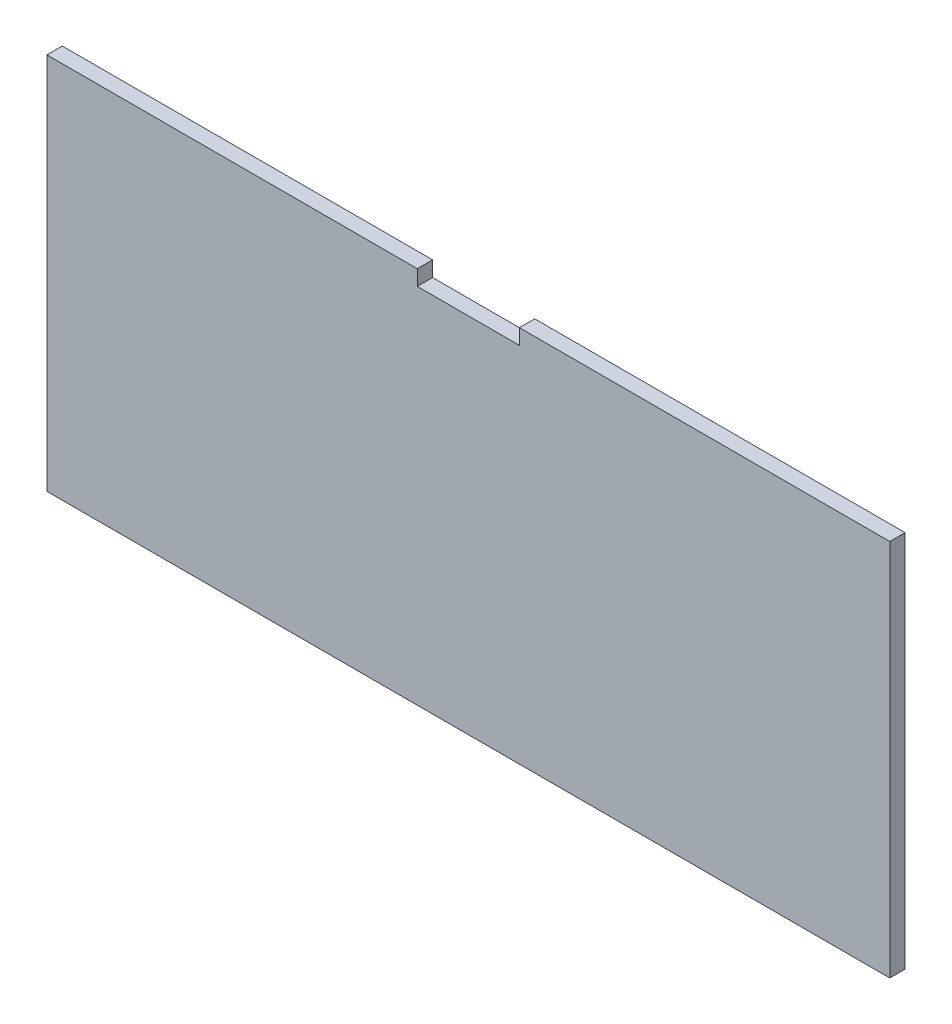
from build123d import *

# Parameters (mm, degrees)
RESSALTO_EXTRUS_O1_DEPTH = 3


with BuildPart() as part:
    # Esboço3 → Ressalto-extrusão1 (new body)
    with BuildSketch(Plane.XY):
        Polygon((-13.361267606, 19.527086248), (-85.861267606, 19.527086248), (-85.861267606, -54.472913752), (79.138732394, -54.472913752), (79.138732394, 19.527086248), (6.638732394, 19.527086248), (6.638732394, 16.527086248), (-13.361267606, 16.527086248), align=None)
    extrude(amount=-RESSALTO_EXTRUS_O1_DEPTH)


solid = part.part
